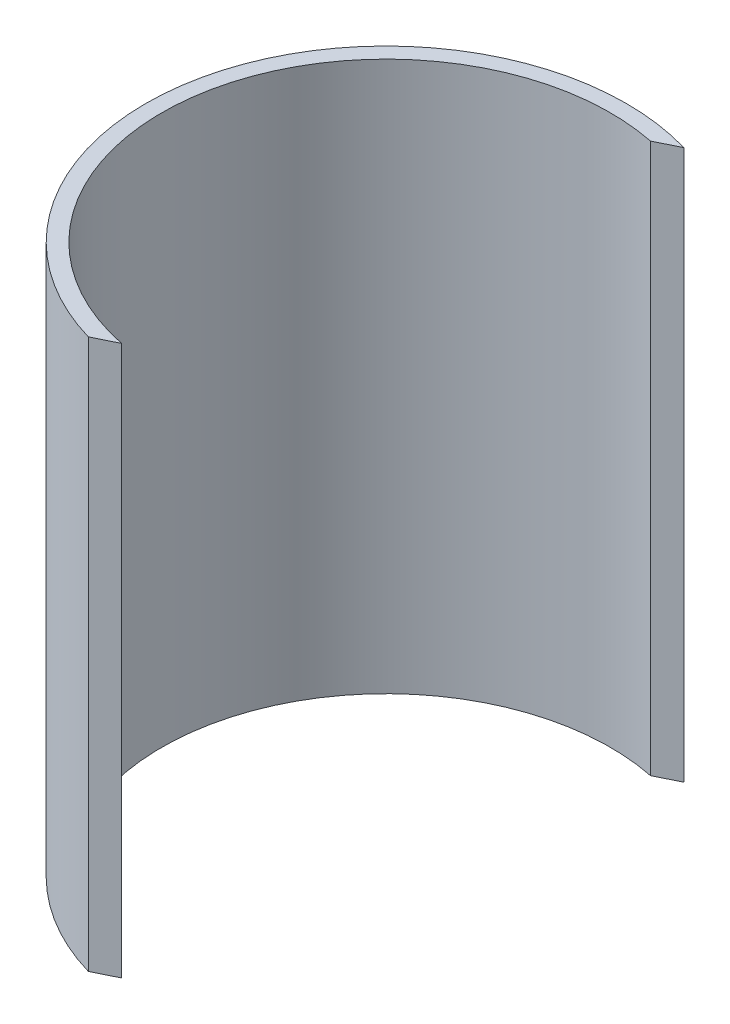
from build123d import *

# Parameters (mm, degrees)
SALIENTE_EXTRUIR4_DEPTH = 63.5


with BuildPart() as part:
    # Croquis2 → Saliente-Extruir4 (new body)
    with BuildSketch(Plane(origin=(0, 0, 0), x_dir=(1, 0, 0), z_dir=(0, 1, 0))):
        with BuildLine():
            Line((7.732159435, 26.67), (5.153784465, 25.4))
            ThreePointArc((5.153784465, 25.4), (-25.4, 5.153784465), (-5.153784465, -25.4))
            Line((-5.153784465, -25.4), (-7.732159435, -26.67))
            ThreePointArc((-7.732159435, -26.67), (-26.67, 7.732159435), (7.732159435, 26.67))
        make_face()
    extrude(amount=SALIENTE_EXTRUIR4_DEPTH)


solid = part.part
